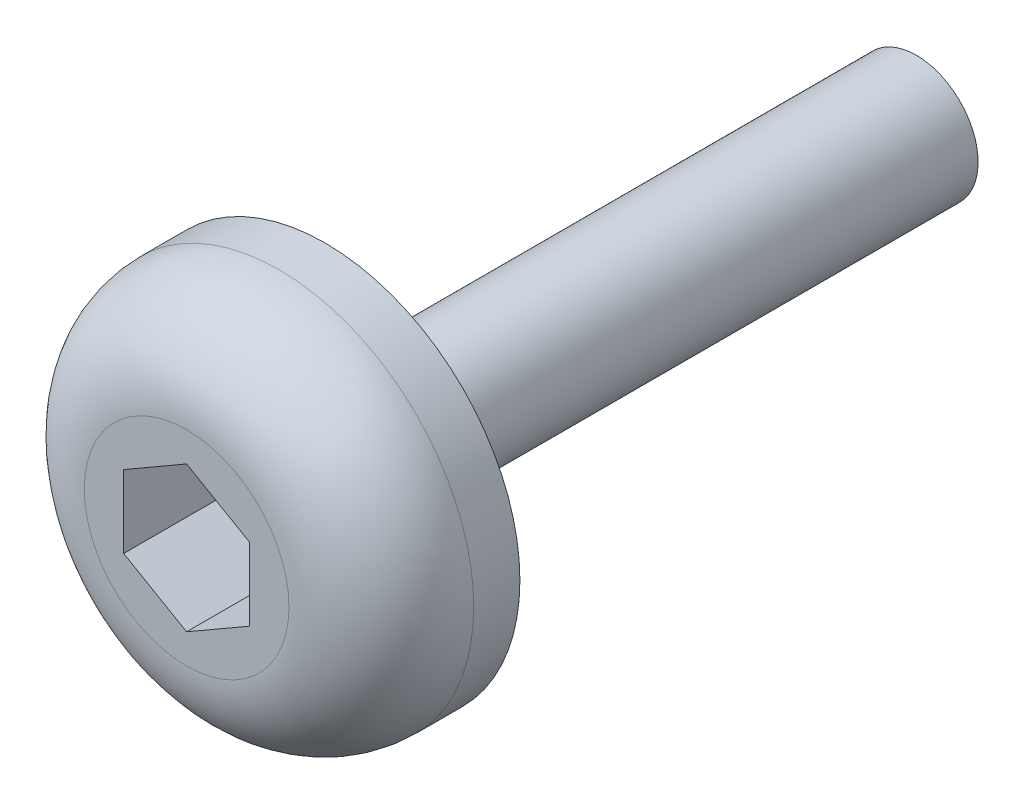
from build123d import *

# Parameters (mm, degrees)
SKETCH1_R           = 5.354341082
BOSS_EXTRUDE1_DEPTH = 3.81
FILLET1_R           = 2.54
CUT_EXTRUDE1_DEPTH  = 2.794
SKETCH3_R           = 1.69700591
BOSS_EXTRUDE2_DEPTH = 16.256


with BuildPart() as part:
    # Sketch1 → Boss-Extrude1 (new body)
    with BuildSketch(Plane.XY):
        Circle(SKETCH1_R)
    extrude(amount=BOSS_EXTRUDE1_DEPTH)

    # Fillet1
    fillet1_edges = [part.edges().sort_by_distance(p)[0] for p in [
        (-5.354341082, 0, 3.81),
    ]]
    fillet(fillet1_edges, radius=FILLET1_R)

    # Sketch2 → Cut-Extrude1 (cut)
    with BuildSketch(Plane.XY.offset(3.81)):
        Polygon((0, 1.998303372), (-1.730581485, 0.999151686), (-1.730581485, -0.999151686), (0, -1.998303372), (1.730581485, -0.999151686), (1.730581485, 0.999151686), align=None)
    extrude(amount=-CUT_EXTRUDE1_DEPTH, mode=Mode.SUBTRACT)

    # Sketch3 → Boss-Extrude2 (add)
    with BuildSketch(Plane(origin=(0, 0, 0), x_dir=(-1, 0, 0), z_dir=(0, 0, -1))):
        Circle(SKETCH3_R)
    extrude(amount=BOSS_EXTRUDE2_DEPTH)


solid = part.part
